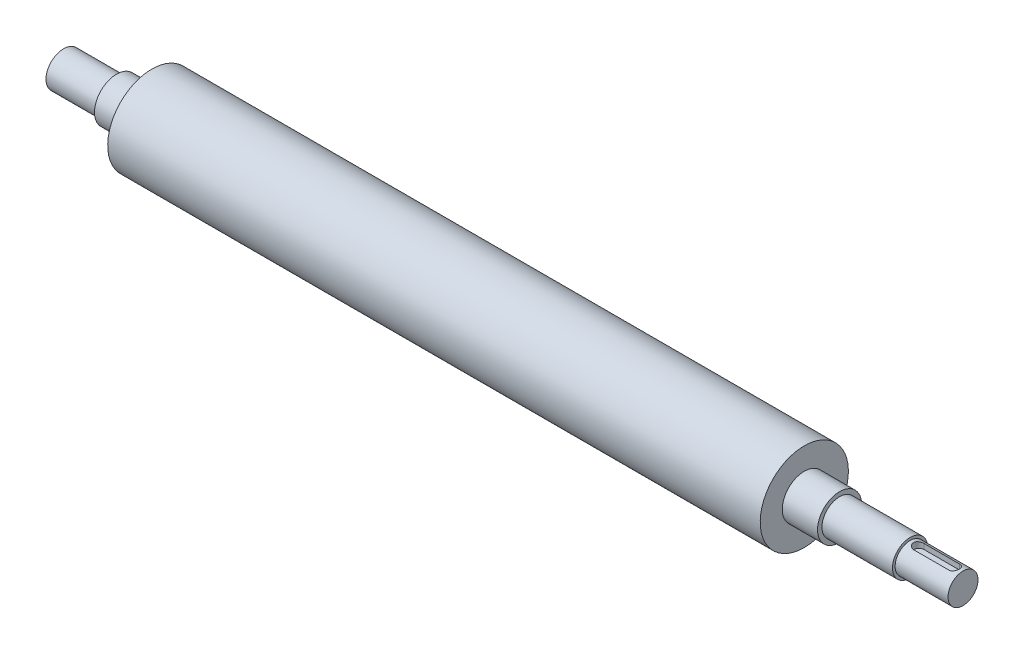
from build123d import *

# Parameters (mm, degrees)
CUT_EXTRUDE_1_DEPTH = 3.5


with BuildPart() as part:
    # 草图1 → 旋转1 (revolve)
    with BuildSketch(Plane.XY):
        Polygon((-185, 25), (185, 25), (185, 12.5), (205, 12.5), (205, 10), (245, 10), (245, 8.5), (275, 8.5), (275, 0), (235, 0), (-235, 0), (-235, 10), (-205, 10), (-205, 12.5), (-185, 12.5), align=None)
    revolve(axis=Axis((-235, 0, 0), (1, 0, 0)))

    # 草图2 → 切除-拉伸1 (cut)
    with BuildSketch(Plane(origin=(0, 8.5, 0), x_dir=(1, 0, 0), z_dir=(0, 1, 0))):
        with BuildLine():
            Line((250, 3), (270, 3))
            ThreePointArc((270, 3), (273, 0), (270, -3))
            Line((270, -3), (250, -3))
            ThreePointArc((250, -3), (247, 0), (250, 3))
        make_face()
    extrude(amount=-CUT_EXTRUDE_1_DEPTH, mode=Mode.SUBTRACT)


solid = part.part
